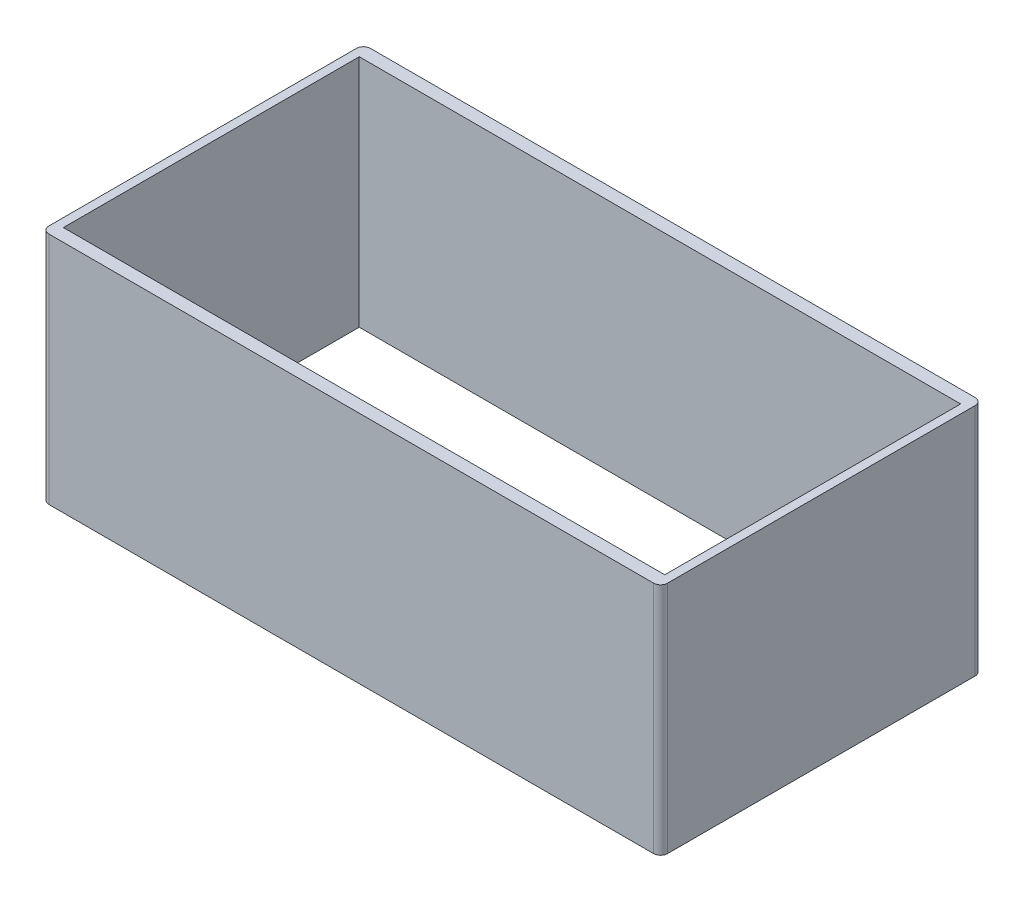
from build123d import *

# Parameters (mm, degrees)
MIDDLE_COVER_SKETCH_01_W    = 44.37
MIDDLE_COVER_SKETCH_01_H    = 23.06
SALIENTE_EXTRUIR1_DEPTH     = 16.8
VACIADO1_T                  = -1
VACIADO1_THICKNESS_2_FACE_W = 21.06
VACIADO1_THICKNESS_2_FACE_H = 16.8
VACIADO1_THICKNESS_2_DEPTH  = 0.38
VACIADO1_THICKNESS_3_FACE_W = 21.06
VACIADO1_THICKNESS_3_FACE_H = 16.8
VACIADO1_THICKNESS_3_DEPTH  = 0.38
VACIADO1_THICKNESS_4_FACE_W = 43.13
VACIADO1_THICKNESS_4_FACE_H = 16.8
VACIADO1_THICKNESS_4_DEPTH  = 0.08
VACIADO1_THICKNESS_5_FACE_W = 43.13
VACIADO1_THICKNESS_5_FACE_H = 16.8
VACIADO1_THICKNESS_5_DEPTH  = 0.08
REDONDEO1_R                 = 0.5


with BuildPart() as part:
    # Middle-cover-sketch-01 → Saliente-Extruir1 (new body)
    with BuildSketch(Plane(origin=(0, 0, 0), x_dir=(1, 0, 0), z_dir=(0, 1, 0))):
        Rectangle(MIDDLE_COVER_SKETCH_01_W, MIDDLE_COVER_SKETCH_01_H)
    extrude(amount=SALIENTE_EXTRUIR1_DEPTH)

    # Vaciado1
    vaciado1_openings = [part.faces().sort_by_distance(p)[0] for p in [
        (0, 16.8, 0),
        (0, 0, 0),
    ]]
    offset(amount=VACIADO1_T, openings=vaciado1_openings, kind=Kind.INTERSECTION)

    # Vaciado1 thickness 2 face (on inner face of the shell) → Vaciado1 thickness 2 (cut)
    with BuildSketch(Plane(origin=(21.185, 8.4, 0), x_dir=(0, 0, 1), z_dir=(1, 0, 0))):
        Rectangle(VACIADO1_THICKNESS_2_FACE_W, VACIADO1_THICKNESS_2_FACE_H)
    extrude(amount=VACIADO1_THICKNESS_2_DEPTH, mode=Mode.SUBTRACT)

    # Vaciado1 thickness 3 face (on inner face of the shell) → Vaciado1 thickness 3 (cut)
    with BuildSketch(Plane(origin=(-21.185, 8.4, 0), x_dir=(0, 0, -1), z_dir=(-1, 0, 0))):
        Rectangle(VACIADO1_THICKNESS_3_FACE_W, VACIADO1_THICKNESS_3_FACE_H)
    extrude(amount=VACIADO1_THICKNESS_3_DEPTH, mode=Mode.SUBTRACT)

    # Vaciado1 thickness 4 face (on inner face of the shell) → Vaciado1 thickness 4 (cut)
    with BuildSketch(Plane(origin=(0, 8.4, 10.53), x_dir=(1, 0, 0), z_dir=(0, 0, 1))):
        Rectangle(VACIADO1_THICKNESS_4_FACE_W, VACIADO1_THICKNESS_4_FACE_H)
    extrude(amount=VACIADO1_THICKNESS_4_DEPTH, mode=Mode.SUBTRACT)

    # Vaciado1 thickness 5 face (on inner face of the shell) → Vaciado1 thickness 5 (cut)
    with BuildSketch(Plane(origin=(0, 8.4, -10.53), x_dir=(-1, 0, 0), z_dir=(0, 0, -1))):
        Rectangle(VACIADO1_THICKNESS_5_FACE_W, VACIADO1_THICKNESS_5_FACE_H)
    extrude(amount=VACIADO1_THICKNESS_5_DEPTH, mode=Mode.SUBTRACT)

    # Redondeo1
    redondeo1_edges = [part.edges().sort_by_distance(p)[0] for p in [
        (-22.185, 8.4, -11.53),
        (22.185, 8.4, -11.53),
        (22.185, 8.4, 11.53),
        (-22.185, 8.4, 11.53),
    ]]
    fillet(redondeo1_edges, radius=REDONDEO1_R)


solid = part.part
